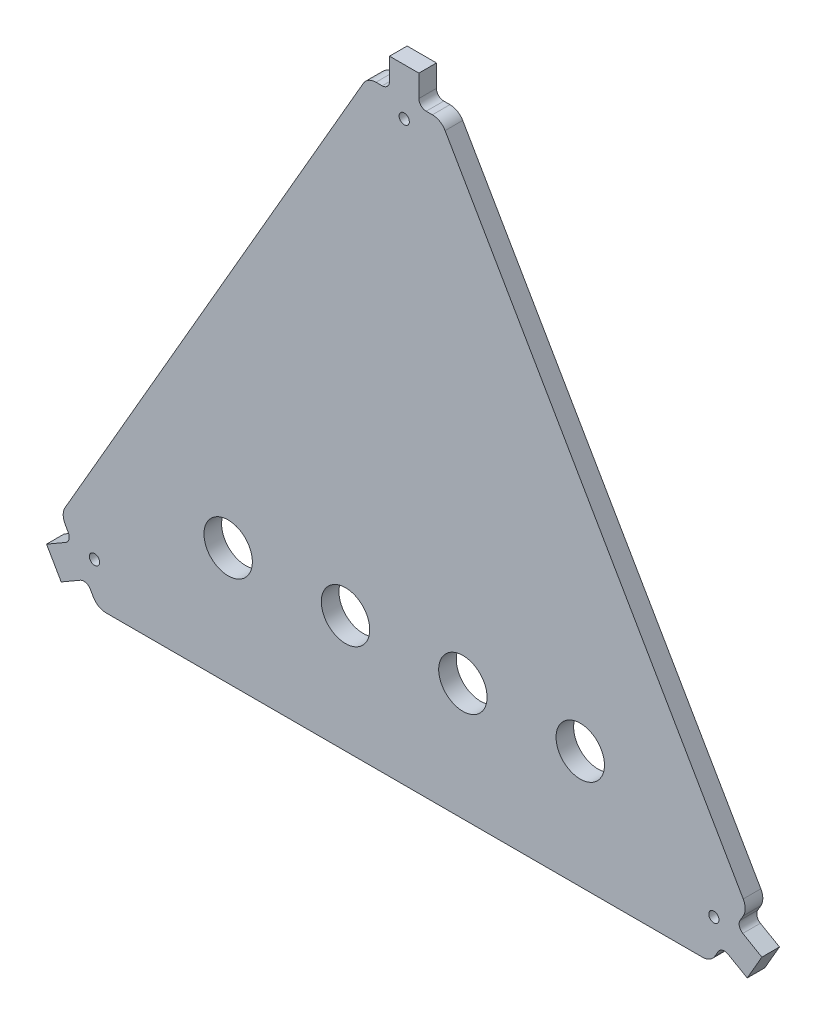
from build123d import *

# Parameters (mm, degrees)
BOSS_EXTRUDE1_DEPTH = 12
CUT_EXTRUDE1_REACH  = 14
SKETCH2_R           = 3.5
FILLET1_R           = 10
CUT_EXTRUDE2_REACH  = 14
SKETCH3_R           = 16.5
SKETCH4_W           = 20
SKETCH4_H           = 20
BOSS_EXTRUDE2_DEPTH = 12
FILLET2_R           = 5


with BuildPart() as part:
    # Sketch1 → Boss-Extrude1 (new body)
    with BuildSketch(Plane.XY):
        Polygon((-209, 0), (209, 0), (234, 43.301270189), (25, 405.299888971), (-25, 405.299888971), (-234, 43.301270189), align=None)
    extrude(amount=BOSS_EXTRUDE1_DEPTH)

    # Sketch2 → Cut-Extrude1 (cut, up to next)
    with BuildSketch(Plane.XY.offset(12), mode=Mode.PRIVATE) as cut_extrude1_sk1:
        with Locations((211.107695155, 27.650635095)):
            Circle(SKETCH2_R)
    cut_extrude1_tool1 = extrude(cut_extrude1_sk1.sketch, amount=-CUT_EXTRUDE1_REACH, mode=Mode.PRIVATE) & part.part
    add(cut_extrude1_tool1.solids().sort_by_distance((211.107695, 27.650635, 12))[0], mode=Mode.SUBTRACT)
    # Sketch2 → Cut-Extrude1 (cut, up to next)
    with BuildSketch(Plane.XY.offset(12), mode=Mode.PRIVATE) as cut_extrude1_sk2:
        with Locations((0, 393.299888971)):
            Circle(SKETCH2_R)
    cut_extrude1_tool2 = extrude(cut_extrude1_sk2.sketch, amount=-CUT_EXTRUDE1_REACH, mode=Mode.PRIVATE) & part.part
    add(cut_extrude1_tool2.solids().sort_by_distance((0, 393.299889, 12))[0], mode=Mode.SUBTRACT)
    # Sketch2 → Cut-Extrude1 (cut, up to next)
    with BuildSketch(Plane.XY.offset(12), mode=Mode.PRIVATE) as cut_extrude1_sk3:
        with Locations((-211.107695155, 27.650635095)):
            Circle(SKETCH2_R)
    cut_extrude1_tool3 = extrude(cut_extrude1_sk3.sketch, amount=-CUT_EXTRUDE1_REACH, mode=Mode.PRIVATE) & part.part
    add(cut_extrude1_tool3.solids().sort_by_distance((-211.107695, 27.650635, 12))[0], mode=Mode.SUBTRACT)

    # Fillet1
    fillet1_edges = [part.edges().sort_by_distance(p)[0] for p in [
        (-25, 405.299888971, 6),
        (25, 405.299888971, 6),
        (234, 43.301270189, 6),
        (209, 0, 6),
        (-209, 0, 6),
        (-234, 43.301270189, 6),
    ]]
    fillet(fillet1_edges, radius=FILLET1_R)

    # Sketch3 → Cut-Extrude2 (cut, up to next)
    with BuildSketch(Plane.XY.offset(12), mode=Mode.PRIVATE) as cut_extrude2_sk1:
        with Locations((-40, 80)):
            Circle(SKETCH3_R)
    cut_extrude2_tool1 = extrude(cut_extrude2_sk1.sketch, amount=-CUT_EXTRUDE2_REACH, mode=Mode.PRIVATE) & part.part
    add(cut_extrude2_tool1.solids().sort_by_distance((-40, 80, 12))[0], mode=Mode.SUBTRACT)
    # Sketch3 → Cut-Extrude2 (cut, up to next)
    with BuildSketch(Plane.XY.offset(12), mode=Mode.PRIVATE) as cut_extrude2_sk2:
        with Locations((40, 80)):
            Circle(SKETCH3_R)
    cut_extrude2_tool2 = extrude(cut_extrude2_sk2.sketch, amount=-CUT_EXTRUDE2_REACH, mode=Mode.PRIVATE) & part.part
    add(cut_extrude2_tool2.solids().sort_by_distance((40, 80, 12))[0], mode=Mode.SUBTRACT)
    # Sketch3 → Cut-Extrude2 (cut, up to next)
    with BuildSketch(Plane.XY.offset(12), mode=Mode.PRIVATE) as cut_extrude2_sk3:
        with Locations((-120, 80)):
            Circle(SKETCH3_R)
    cut_extrude2_tool3 = extrude(cut_extrude2_sk3.sketch, amount=-CUT_EXTRUDE2_REACH, mode=Mode.PRIVATE) & part.part
    add(cut_extrude2_tool3.solids().sort_by_distance((-120, 80, 12))[0], mode=Mode.SUBTRACT)
    # Sketch3 → Cut-Extrude2 (cut, up to next)
    with BuildSketch(Plane.XY.offset(12), mode=Mode.PRIVATE) as cut_extrude2_sk4:
        with Locations((120, 80)):
            Circle(SKETCH3_R)
    cut_extrude2_tool4 = extrude(cut_extrude2_sk4.sketch, amount=-CUT_EXTRUDE2_REACH, mode=Mode.PRIVATE) & part.part
    add(cut_extrude2_tool4.solids().sort_by_distance((120, 80, 12))[0], mode=Mode.SUBTRACT)

    # Sketch4 → Boss-Extrude2 (add)
    with BuildSketch(Plane.XY.offset(12)):
        with Locations((0, 415.299888971)):
            Rectangle(SKETCH4_W, SKETCH4_H)
        Polygon((226.5, 30.310889132), (243.820508076, 20.310889132), (233.820508076, 2.990381057), (216.5, 12.990381057), align=None)
        Polygon((-226.5, 30.310889132), (-243.820508076, 20.310889132), (-233.820508076, 2.990381057), (-216.5, 12.990381057), align=None)
    extrude(amount=-BOSS_EXTRUDE2_DEPTH)

    # Fillet2
    fillet2_edges = [part.edges().sort_by_distance(p)[0] for p in [
        (216.5, 12.990381057, 6),
        (226.5, 30.310889132, 6),
        (-226.5, 30.310889132, 6),
        (-216.5, 12.990381057, 6),
        (10, 405.299888971, 6),
        (-10, 405.299888971, 6),
    ]]
    fillet(fillet2_edges, radius=FILLET2_R)


solid = part.part
